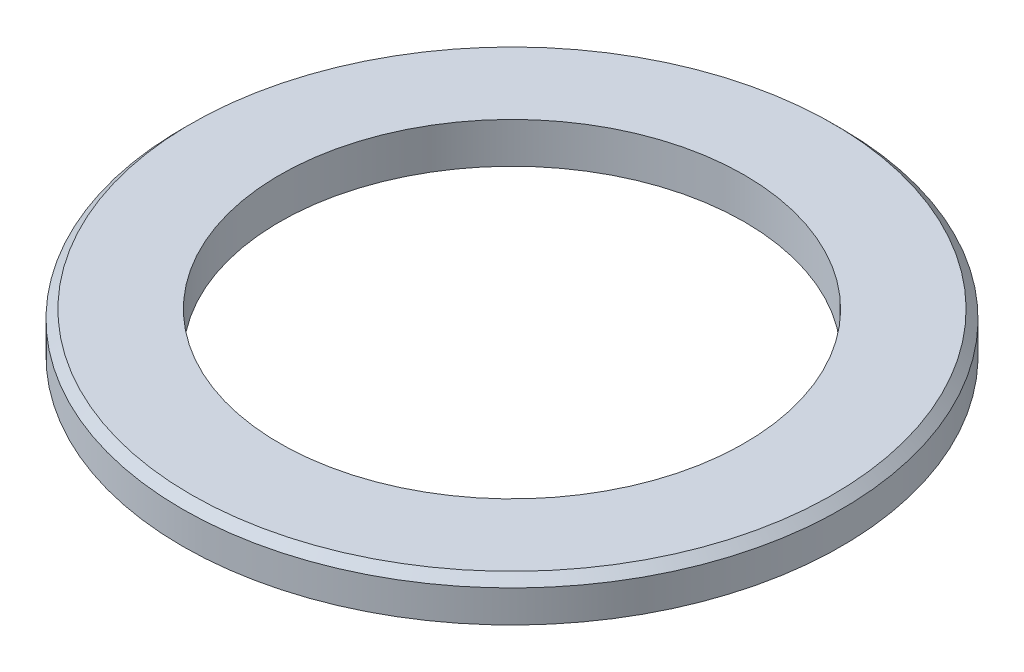
from build123d import *

# Parameters (mm, degrees)
CHAMFER1_SIZE = 1


with BuildPart() as part:
    # Sketch1 → Revolve1 (revolve)
    with BuildSketch(Plane.XY):
        with BuildLine():
            Line((27.5, 0), (29.936442743, 0))
            ThreePointArc((29.936442743, 0), (32.167974855, 0.680321637), (34.399506968, 0))
            Line((34.399506968, 0), (39, 0))
            Line((39, 0), (39, 4.8))
            Line((39, 4.8), (27.5, 4.8))
            Line((27.5, 4.8), (27.5, 0))
        make_face()
    revolve(axis=Axis((0, 0, 0), (0, 1, 0)))

    # Chamfer1
    chamfer1_edges = [part.edges().sort_by_distance(p)[0] for p in [
        (-39, 4.8, 0),
    ]]
    chamfer(chamfer1_edges, length=CHAMFER1_SIZE)


solid = part.part
